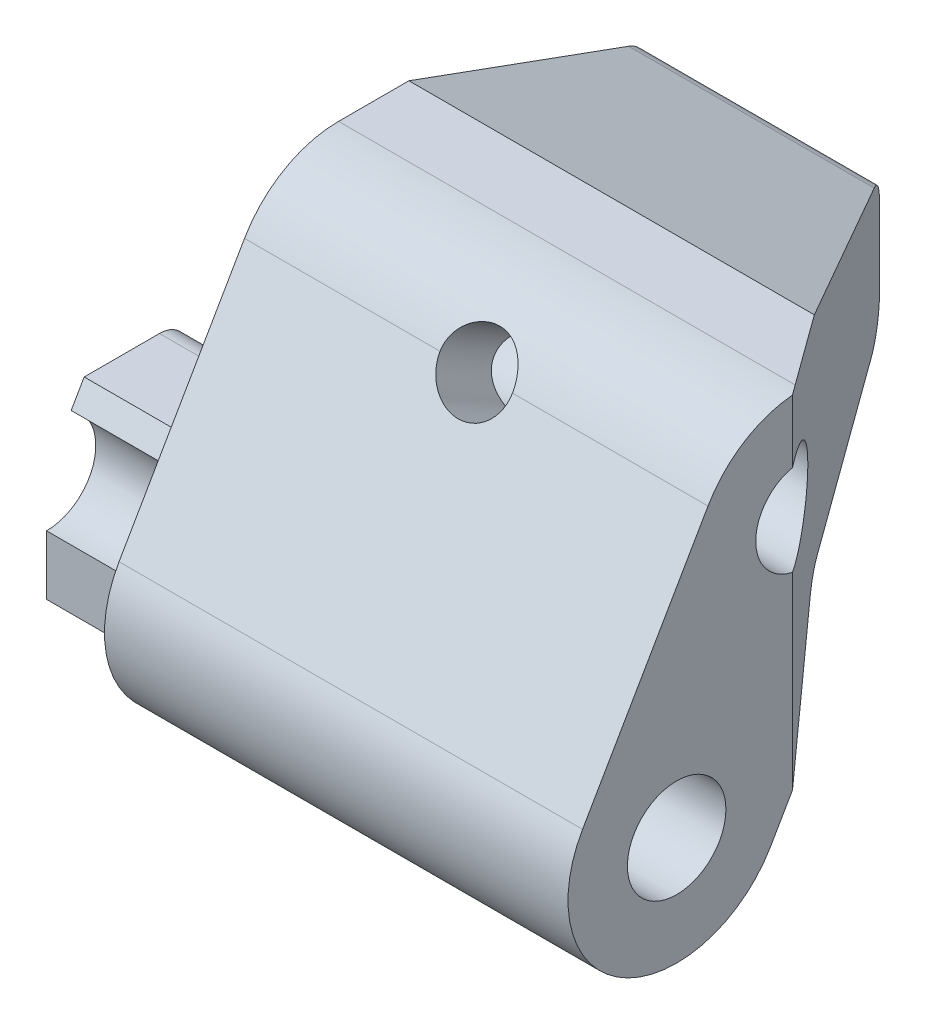
from build123d import *

# Parameters (mm, degrees)
SKETCH1_R               = 1.7
SKETCH1_R_2             = 1.6
BOSS_EXTRUDE1_DEPTH     = 22
CUT_EXTRUDE1_DEPTH      = 6
CUT_EXTRUDE2_START      = -2
CUT_EXTRUDE2_DEPTH      = 5
CHAMFER1_SIZE           = 3
CHAMFER1_SIZE2          = 8.242432258
SKETCH4_R               = 2.2
SKETCH4_R_2             = 1.6
BOSS_EXTRUDE2_DEPTH     = 0.15
SKETCH5_R               = 7.371028059
CUT_EXTRUDE3_DEPTH      = 0.25
FILLET1_R               = 1
CUT_EXTRUDE4_DEPTH      = 12.25
CUT_EXTRUDE4_DEPTH_BACK = 4.75
SKETCH8_W               = 8
SKETCH8_H               = 3
BOSS_EXTRUDE4_DEPTH     = 1
SKETCH10_R              = 1.25
CUT_EXTRUDE7_DEPTH      = 4
SKETCH11_W              = 5
SKETCH11_H              = 3
BOSS_EXTRUDE5_DEPTH     = 1


with BuildPart() as part:
    # Sketch1 → Boss-Extrude1 (new body)
    with BuildSketch(Plane(origin=(0, 0, 0), x_dir=(0, 0, -1), z_dir=(1, 0, 0))):
        with BuildLine():
            Line((-3.247595264, 1.875), (1.082531755, 9.375))
            ThreePointArc((1.082531755, 9.375), (2.455127019, 10.747595264), (4.330127019, 11.25))
            Line((4.330127019, 11.25), (15, 11.25))
            Line((15, 11.25), (15, 3.75))
            Line((15, 3.75), (6.495190528, 3.75))
            Line((6.495190528, 3.75), (3.247595264, -1.875))
            ThreePointArc((3.247595264, -1.875), (-1.875, -3.247595264), (-3.247595264, 1.875))
        make_face()
        Circle(SKETCH1_R, mode=Mode.SUBTRACT)
        with Locations((4.330127019, 7.5)):
            Circle(SKETCH1_R_2, mode=Mode.SUBTRACT)
    extrude(amount=BOSS_EXTRUDE1_DEPTH)

    # Sketch2 → Cut-Extrude1 (cut)
    with BuildSketch(Plane.ZY):
        Polygon((-15, 11.25), (5.328677025, 11.25), (5.328677025, -6.255762667), (0, -6.255762667), (0, 0), (-1.299038106, 2.25), (-5.629165125, 2.25), (-15, 2.25), align=None)
    extrude(amount=-CUT_EXTRUDE1_DEPTH, mode=Mode.SUBTRACT)

    # Sketch3 → Cut-Extrude2 (cut)
    with BuildSketch(Plane(origin=(0, 0, -15), x_dir=(-1, 0, 0), z_dir=(0, 0, -1)).offset(CUT_EXTRUDE2_START)):
        with BuildLine():
            Line((-19.5, 3.75), (-19.5, 5.15))
            ThreePointArc((-19.5, 5.15), (-19.03137085, 6.28137085), (-17.9, 6.75))
            Line((-17.9, 6.75), (-10.1, 6.75))
            Line((-10.1, 6.75), (-6, 6.75))
            Line((-6, 6.75), (-6, 3.75))
            Line((-6, 3.75), (-8.5, 3.75))
            Line((-8.5, 3.75), (-19.5, 3.75))
        make_face()
    extrude(amount=-CUT_EXTRUDE2_DEPTH, mode=Mode.SUBTRACT)

    # Chamfer1
    chamfer1_edges = [part.edges().sort_by_distance(p)[0] for p in [
        (14, 11.25, -15),
    ]]
    chamfer1_side = [part.faces().sort_by_distance(p)[0] for p in [
        (14, 7.5, -15),
    ]]
    chamfer(chamfer1_edges, length=CHAMFER1_SIZE, length2=CHAMFER1_SIZE2, reference=chamfer1_side[0])

    # Sketch4 → Boss-Extrude2 (add)
    with BuildSketch(Plane.ZY.offset(-6)):
        with Locations((-4.330127019, 7.5)):
            Circle(SKETCH4_R)
        with Locations((-4.330127019, 7.5)):
            Circle(SKETCH4_R_2, mode=Mode.SUBTRACT)
    extrude(amount=BOSS_EXTRUDE2_DEPTH)

    # Sketch5 → Cut-Extrude3 (cut)
    with BuildSketch(Plane.ZY):
        Circle(SKETCH5_R)
    extrude(amount=-CUT_EXTRUDE3_DEPTH, mode=Mode.SUBTRACT)

    # Fillet1
    fillet1_edges = [part.edges().sort_by_distance(p)[0] for p in [
        (3.125, 2.25, -5.629165125),
        (14, 3.75, -15),
        (14, 3.75, -6.495190528),
        (14, 8.25, -15),
    ]]
    fillet(fillet1_edges, radius=FILLET1_R)

    # Sketch7 → Cut-Extrude4 (cut, two sides)
    with BuildSketch(Plane(origin=(0, 0, 0), x_dir=(1, 0, 0), z_dir=(0, 1, 0))) as cut_extrude4_sk:
        Polygon((22, 4), (14, 15), (22, 15), align=None)
    extrude(amount=CUT_EXTRUDE4_DEPTH, mode=Mode.SUBTRACT)
    extrude(cut_extrude4_sk.sketch, amount=-CUT_EXTRUDE4_DEPTH_BACK, mode=Mode.SUBTRACT)

    # Sketch8 → Boss-Extrude4 (add)
    with BuildSketch(Plane(origin=(16.291891892, 0, -11.848648649), x_dir=(-0.588171698, 0, -0.808736084), z_dir=(0.808736084, 0, -0.588171698))):
        with Locations((-1.339859822, 5.25)):
            Rectangle(SKETCH8_W, SKETCH8_H)
    extrude(amount=-BOSS_EXTRUDE4_DEPTH)

    # Sketch10 → Cut-Extrude7 (cut)
    with BuildSketch(Plane(origin=(0, 1.875, 3.247595264), x_dir=(1, 0, 0), z_dir=(0, 0.5, 0.866025404))):
        with Locations((14, 8.660254038)):
            Circle(SKETCH10_R)
    extrude(amount=-CUT_EXTRUDE7_DEPTH, mode=Mode.SUBTRACT)

    # Sketch11 → Boss-Extrude5 (add)
    with BuildSketch(Plane.ZY.offset(-6)):
        with Locations((-10.5, 5.25)):
            Rectangle(SKETCH11_W, SKETCH11_H)
    extrude(amount=-BOSS_EXTRUDE5_DEPTH)


solid = part.part
